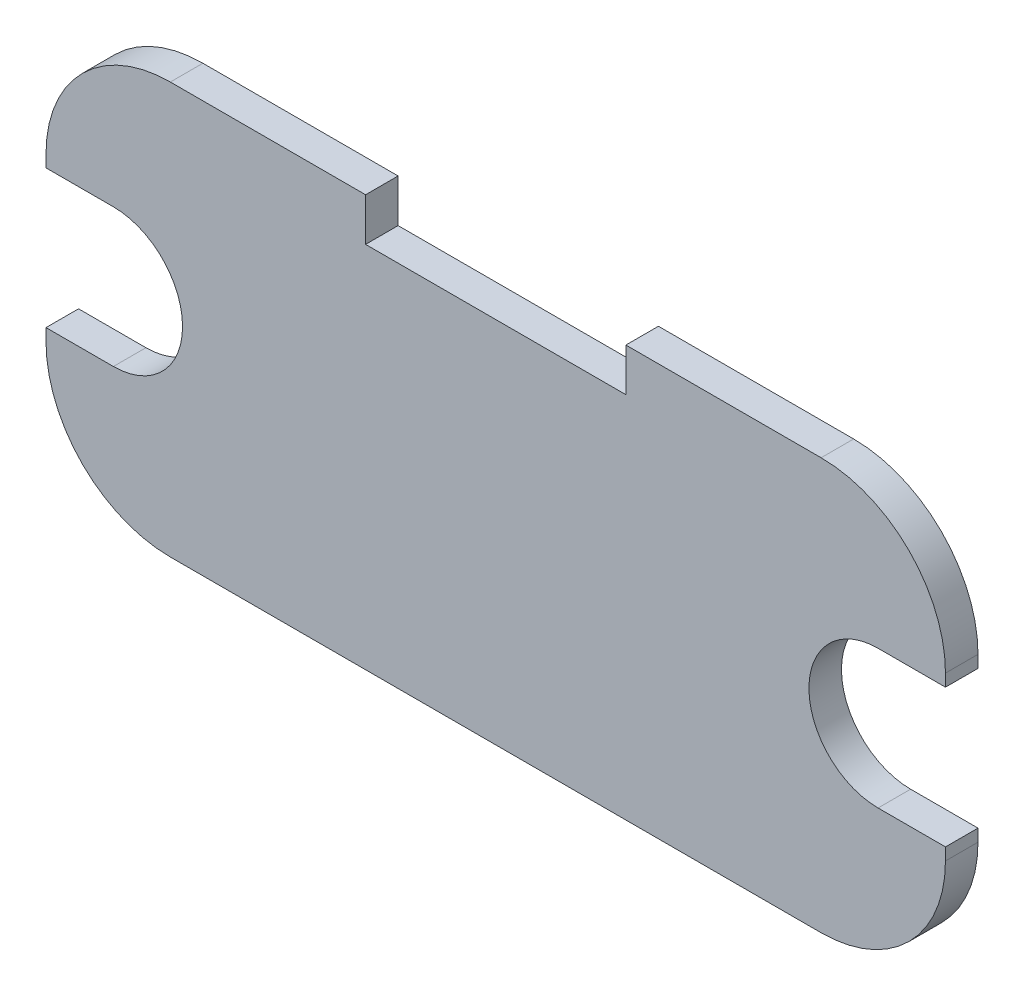
from build123d import *

# Parameters (mm, degrees)
SKETCH_1_R          = 3.25
EXTRUDE_1_DEPTH     = 2
CUT_EXTRUDE_2_DEPTH = 2


with BuildPart() as part:
    # Эскиз1 → Бобышка-Вытянуть1 (new body)
    with BuildSketch(Plane.XY):
        with BuildLine():
            Line((-8, 15.642410702), (-20, 15.642410702))
            ThreePointArc((-20, 15.642410702), (-25.404000432, 13.404000432), (-27.642410702, 8))
            Line((-27.642410702, 8), (-27.642410702, -2))
            ThreePointArc((-27.642410702, -2), (-25.404000432, -7.404000432), (-20, -9.642410702))
            Line((-20, -9.642410702), (20, -9.642410702))
            ThreePointArc((20, -9.642410702), (25.404000432, -7.404000432), (27.642410702, -2))
            Line((27.642410702, -2), (27.642410702, 8))
            ThreePointArc((27.642410702, 8), (25.404000432, 13.404000432), (20, 15.642410702))
            Line((20, 15.642410702), (8, 15.642410702))
            Line((8, 15.642410702), (8, 13))
            Line((8, 13), (-8, 13))
            Line((-8, 13), (-8, 15.642410702))
        make_face()
        with Locations((23.5, 3)):
            Circle(SKETCH_1_R, mode=Mode.SUBTRACT)
        with Locations((-23.5, 3)):
            Circle(SKETCH_1_R, mode=Mode.SUBTRACT)
    extrude(amount=EXTRUDE_1_DEPTH)

    # Эскиз3 → Вырез-Вытянуть2 (cut)
    with BuildSketch(Plane.XY.offset(2)):
        with BuildLine():
            Line((-23.5, -1.25), (-30.303484741, -1.25))
            ThreePointArc((-30.303484741, -1.25), (-34.553484741, 3), (-30.303484741, 7.25))
            Line((-30.303484741, 7.25), (-23.5, 7.25))
            ThreePointArc((-23.5, 7.25), (-19.25, 3), (-23.5, -1.25))
        make_face()
        with BuildLine():
            Line((23.5, -1.25), (30.303484741, -1.25))
            ThreePointArc((30.303484741, -1.25), (34.553484741, 3), (30.303484741, 7.25))
            Line((30.303484741, 7.25), (23.5, 7.25))
            ThreePointArc((23.5, 7.25), (19.25, 3), (23.5, -1.25))
        make_face()
    extrude(amount=-CUT_EXTRUDE_2_DEPTH, mode=Mode.SUBTRACT)


solid = part.part
